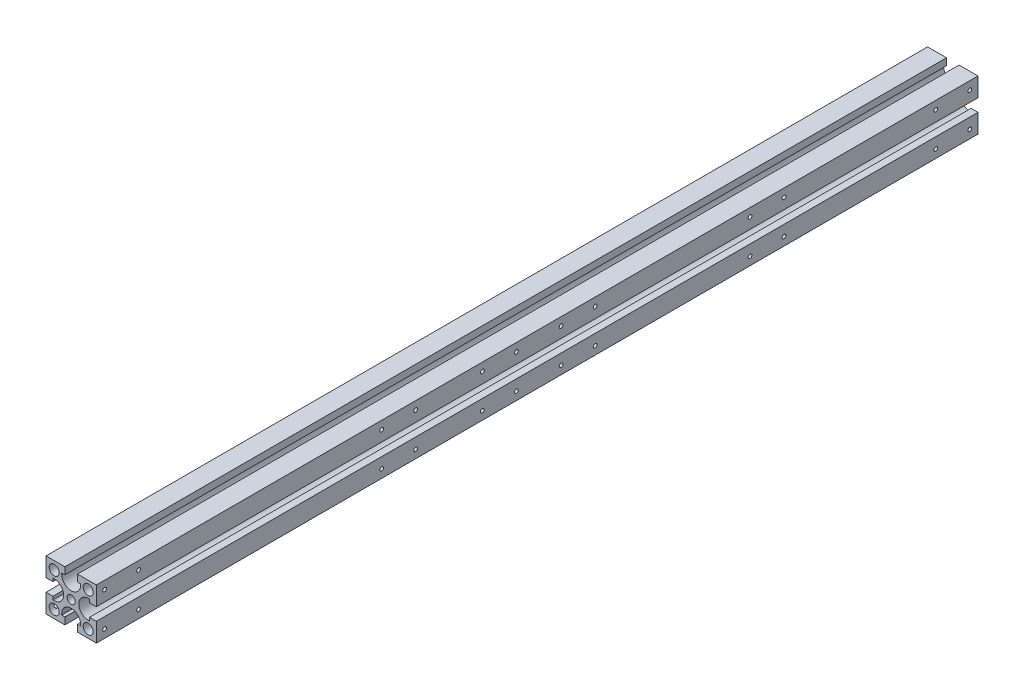
from build123d import *

# Parameters (mm, degrees)
SKETCH_1_W           = 40
SKETCH_1_H           = 40
EXTRUDE_1_DEPTH      = 700
SKETCH_2_R           = 3.25
SKETCH_2_R_2         = 4
CUT_EXTRUDE_1_DEPTH  = 701
M3X0_5_1_D           = 2.5
M3X0_5_1_DEPTH       = 7.5
M3X0_5_1_CBORE_D     = 3
M3X0_5_1_CBORE_DEPTH = 6
M3X0_5_1_TIP         = 0.751075774
M3X0_5_2_D           = 2.5
M3X0_5_2_DEPTH       = 7.5
M3X0_5_2_CBORE_D     = 3
M3X0_5_2_CBORE_DEPTH = 6
M3X0_5_2_TIP         = 0.751075774


with BuildPart() as part:
    # 草圖1 → 伸長1 (new body)
    with BuildSketch(Plane.XY):
        Rectangle(SKETCH_1_W, SKETCH_1_H)
    extrude(amount=EXTRUDE_1_DEPTH)

    # 草圖2 → 除料-伸長1 (cut, through all)
    with BuildSketch(Plane(origin=(0, 0, 0), x_dir=(-1, 0, 0), z_dir=(0, 0, -1))):
        Circle(SKETCH_2_R)
        with Locations((-13.5, 13.5)):
            Circle(SKETCH_2_R_2)
        with Locations((13.5, 13.5)):
            Circle(SKETCH_2_R_2)
        with Locations((-13.5, -13.5)):
            Circle(SKETCH_2_R_2)
        with Locations((13.5, -13.5)):
            Circle(SKETCH_2_R_2)
        with BuildLine():
            Line((5, 14.5), (7.5, 14.5))
            Line((7.5, 14.5), (7.5, 13.5))
            ThreePointArc((7.5, 13.5), (0, 6), (-7.5, 13.5))
            Line((-7.5, 13.5), (-7.5, 14.5))
            Line((-7.5, 14.5), (-5, 14.5))
            Line((-5, 14.5), (-5, 20))
            Line((-5, 20), (5, 20))
            Line((5, 20), (5, 14.5))
        make_face()
        with BuildLine():
            Line((14.5, -5), (14.5, -7.5))
            Line((14.5, -7.5), (13.5, -7.5))
            ThreePointArc((13.5, -7.5), (6, 0), (13.5, 7.5))
            Line((13.5, 7.5), (14.5, 7.5))
            Line((14.5, 7.5), (14.5, 5))
            Line((14.5, 5), (20, 5))
            Line((20, 5), (20, -5))
            Line((20, -5), (14.5, -5))
        make_face()
        with BuildLine():
            Line((-5, -14.5), (-7.5, -14.5))
            Line((-7.5, -14.5), (-7.5, -13.5))
            ThreePointArc((-7.5, -13.5), (0, -6), (7.5, -13.5))
            Line((7.5, -13.5), (7.5, -14.5))
            Line((7.5, -14.5), (5, -14.5))
            Line((5, -14.5), (5, -20))
            Line((5, -20), (-5, -20))
            Line((-5, -20), (-5, -14.5))
        make_face()
        with BuildLine():
            Line((-14.5, 5), (-14.5, 7.5))
            Line((-14.5, 7.5), (-13.5, 7.5))
            ThreePointArc((-13.5, 7.5), (-6, 0), (-13.5, -7.5))
            Line((-13.5, -7.5), (-14.5, -7.5))
            Line((-14.5, -7.5), (-14.5, -5))
            Line((-14.5, -5), (-20, -5))
            Line((-20, -5), (-20, 5))
            Line((-20, 5), (-14.5, 5))
        make_face()
    extrude(amount=-CUT_EXTRUDE_1_DEPTH, mode=Mode.SUBTRACT)

    # M3x0.5 螺紋孔1
    with Locations(Plane.ZY.offset(20)):
        with Locations((6.5, 13.5), (33.5, 13.5), (176.5, 13.5), (203.5, 13.5), (203.5, -13.5), (176.5, -13.5), (33.5, -13.5), (6.5, -13.5), (695, 15), (520, 15), (520, -15), (695, -15)):
            CounterBoreHole(M3X0_5_1_D / 2, M3X0_5_1_CBORE_D / 2, M3X0_5_1_CBORE_DEPTH, depth=M3X0_5_1_DEPTH)
            with Locations((0, 0, -(M3X0_5_1_DEPTH + M3X0_5_1_TIP / 2))):  # 118° drill point
                Cone(0, M3X0_5_1_D / 2, M3X0_5_1_TIP, mode=Mode.SUBTRACT)

    # M3x0.5 螺紋孔2
    with Locations(Plane(origin=(20, 0, 0), x_dir=(0, 0, -1), z_dir=(1, 0, 0))):
        with Locations((-693.5, -13.5), (-666.5, -13.5), (-446.5, -13.5), (-473.5, -13.5), (-304, -13.5), (-331, -13.5), (-154, -13.5), (-181, -13.5), (-6.5, -13.5), (-33.5, -13.5), (-393.5, -13.5), (-366.5, -13.5), (-366.5, 13.5), (-393.5, 13.5), (-33.5, 13.5), (-6.5, 13.5), (-181, 13.5), (-154, 13.5), (-331, 13.5), (-304, 13.5), (-473.5, 13.5), (-446.5, 13.5), (-666.5, 13.5), (-693.5, 13.5)):
            CounterBoreHole(M3X0_5_2_D / 2, M3X0_5_2_CBORE_D / 2, M3X0_5_2_CBORE_DEPTH, depth=M3X0_5_2_DEPTH)
            with Locations((0, 0, -(M3X0_5_2_DEPTH + M3X0_5_2_TIP / 2))):  # 118° drill point
                Cone(0, M3X0_5_2_D / 2, M3X0_5_2_TIP, mode=Mode.SUBTRACT)


solid = part.part
